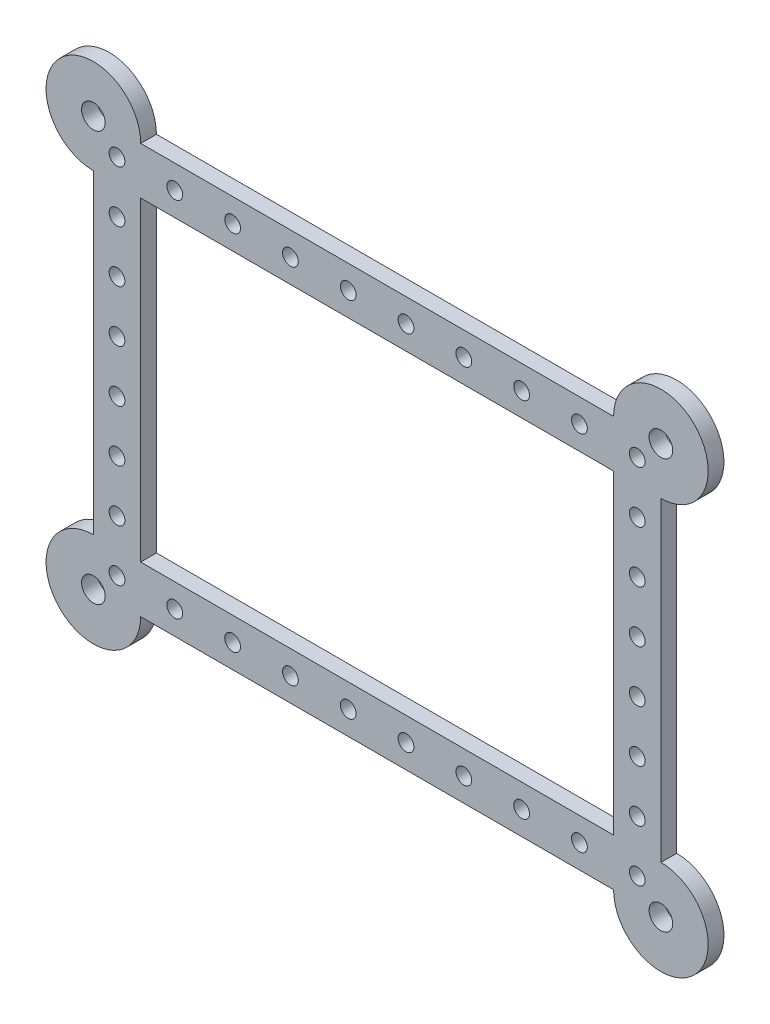
from build123d import *

# Parameters (mm, degrees)
SKETCH1_W          = 120
SKETCH1_H          = 80
FRAME_DEPTH        = 4
SKETCH3_R          = 2
CUT_EXTRUDE1_DEPTH = 4
CRVPATTERN2_COUNT  = 10
CRVPATTERN2_PITCH  = 14.666666667
CRVPATTERN3_COUNT  = 8
CRVPATTERN3_PITCH  = 13.142857143
SKETCH4_R          = 2
CUT_EXTRUDE2_DEPTH = 4
CRVPATTERN5_COUNT  = 10
CRVPATTERN5_PITCH  = 14.666666667
CRVPATTERN6_COUNT  = 8
CRVPATTERN6_PITCH  = 13.142857143
SKETCH12_R         = 3
CUT_EXTRUDE4_DEPTH = 10


with BuildPart() as part:
    # Sketch1 → Frame (new body)
    with BuildSketch(Plane.XY):
        with BuildLine():
            Line((0, -12), (120, -12))
            ThreePointArc((120, -12), (140.485281374, -20.485281374), (132, 0))
            Line((132, 0), (132, 80))
            ThreePointArc((132, 80), (140.485281374, 100.485281374), (120, 92))
            Line((120, 92), (0, 92))
            ThreePointArc((0, 92), (-20.485281374, 100.485281374), (-12, 80))
            Line((-12, 80), (-12, 0))
            ThreePointArc((-12, 0), (-20.485281374, -20.485281374), (0, -12))
        make_face()
        with Locations((60, 40)):
            Rectangle(SKETCH1_W, SKETCH1_H, mode=Mode.SUBTRACT)
    extrude(amount=FRAME_DEPTH)

    # Sketch3 → Cut-Extrude1 (cut)
    with BuildSketch(Plane(origin=(0, 0, 0), x_dir=(-1, 0, 0), z_dir=(0, 0, -1))):
        with Locations((-126, 86)):
            Circle(SKETCH3_R)
    cut_extrude1 = extrude(amount=-CUT_EXTRUDE1_DEPTH, mode=Mode.SUBTRACT)

    # CrvPattern2: Cut-Extrude1 ×10, 1 skipped
    with Locations(*[(-i * CRVPATTERN2_PITCH, 0, 0) for i in range(1, CRVPATTERN2_COUNT) if i not in (9,)]):
        add(cut_extrude1, mode=Mode.SUBTRACT)

    # CrvPattern3: Cut-Extrude1 ×8, 1 skipped
    with Locations(*[(0, -i * CRVPATTERN3_PITCH, 0) for i in range(1, CRVPATTERN3_COUNT) if i not in (7,)]):
        add(cut_extrude1, mode=Mode.SUBTRACT)

    # Sketch4 → Cut-Extrude2 (cut)
    with BuildSketch(Plane(origin=(0, 0, 0), x_dir=(-1, 0, 0), z_dir=(0, 0, -1))):
        with Locations((6, -6)):
            Circle(SKETCH4_R)
    cut_extrude2 = extrude(amount=-CUT_EXTRUDE2_DEPTH, mode=Mode.SUBTRACT)

    # CrvPattern5: Cut-Extrude2 ×10
    with Locations(*[(i * CRVPATTERN5_PITCH, 0, 0) for i in range(1, CRVPATTERN5_COUNT)]):
        add(cut_extrude2, mode=Mode.SUBTRACT)

    # CrvPattern6: Cut-Extrude2 ×8
    with Locations(*[(0, i * CRVPATTERN6_PITCH, 0) for i in range(1, CRVPATTERN6_COUNT)]):
        add(cut_extrude2, mode=Mode.SUBTRACT)

    # Sketch12 → Cut-Extrude4 (cut)
    with BuildSketch(Plane(origin=(0, 0, 0), x_dir=(-1, 0, 0), z_dir=(0, 0, -1))):
        with Locations((-132, 92)):
            Circle(SKETCH12_R)
        with Locations((12, 92)):
            Circle(SKETCH12_R)
        with Locations((12, -12)):
            Circle(SKETCH12_R)
        with Locations((-132, -12)):
            Circle(SKETCH12_R)
    extrude(amount=-CUT_EXTRUDE4_DEPTH, mode=Mode.SUBTRACT)


solid = part.part
